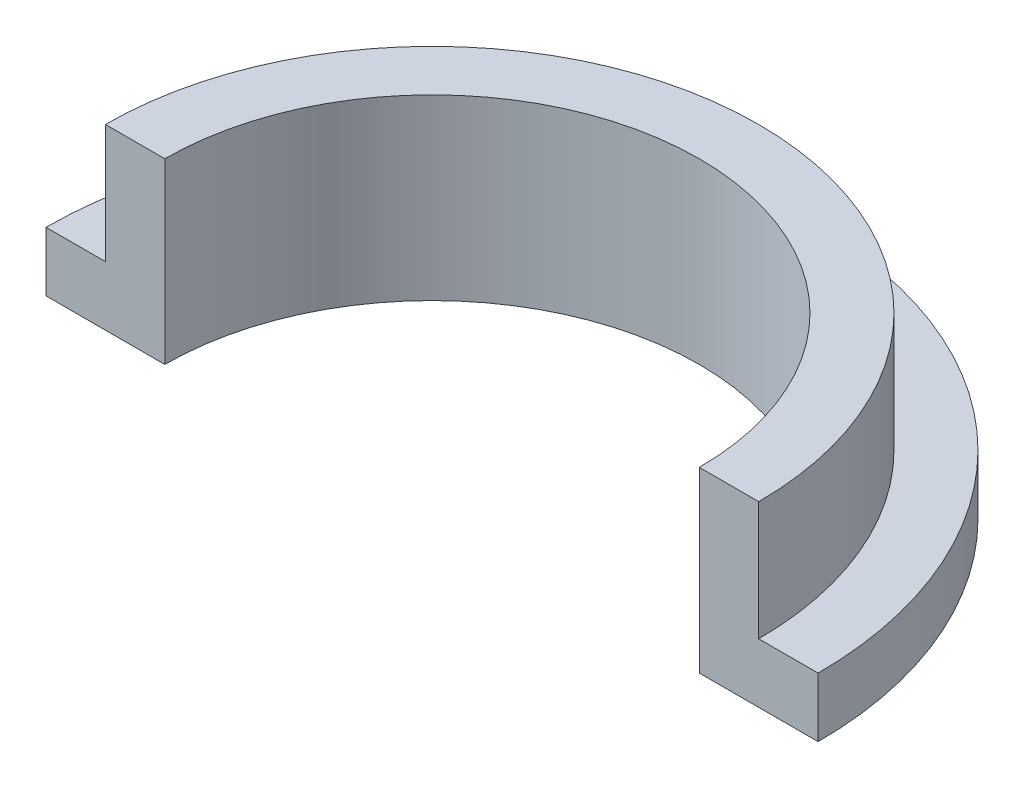
from build123d import *

# Parameters (mm, degrees)
BOSS_EXTRUDE1_DEPTH = 6
CUT_EXTRUDE1_DEPTH  = 4


with BuildPart() as part:
    # Sketch1 → Boss-Extrude1 (new body)
    with BuildSketch(Plane(origin=(0, 0, 0), x_dir=(1, 0, 0), z_dir=(0, 1, 0))):
        with BuildLine():
            Line((-13, 0), (-9, 0))
            ThreePointArc((-9, 0), (0, 9), (9, 0))
            Line((9, 0), (13, 0))
            ThreePointArc((13, 0), (0, 13), (-13, 0))
        make_face()
    extrude(amount=BOSS_EXTRUDE1_DEPTH)

    # Sketch2 → Cut-Extrude1 (cut)
    with BuildSketch(Plane(origin=(0, 6, 0), x_dir=(1, 0, 0), z_dir=(0, 1, 0))):
        with BuildLine():
            Line((-13, 0), (-11, 0))
            ThreePointArc((-11, 0), (0, 11), (11, 0))
            Line((11, 0), (13, 0))
            ThreePointArc((13, 0), (0, 13), (-13, 0))
        make_face()
    extrude(amount=-CUT_EXTRUDE1_DEPTH, mode=Mode.SUBTRACT)


solid = part.part
